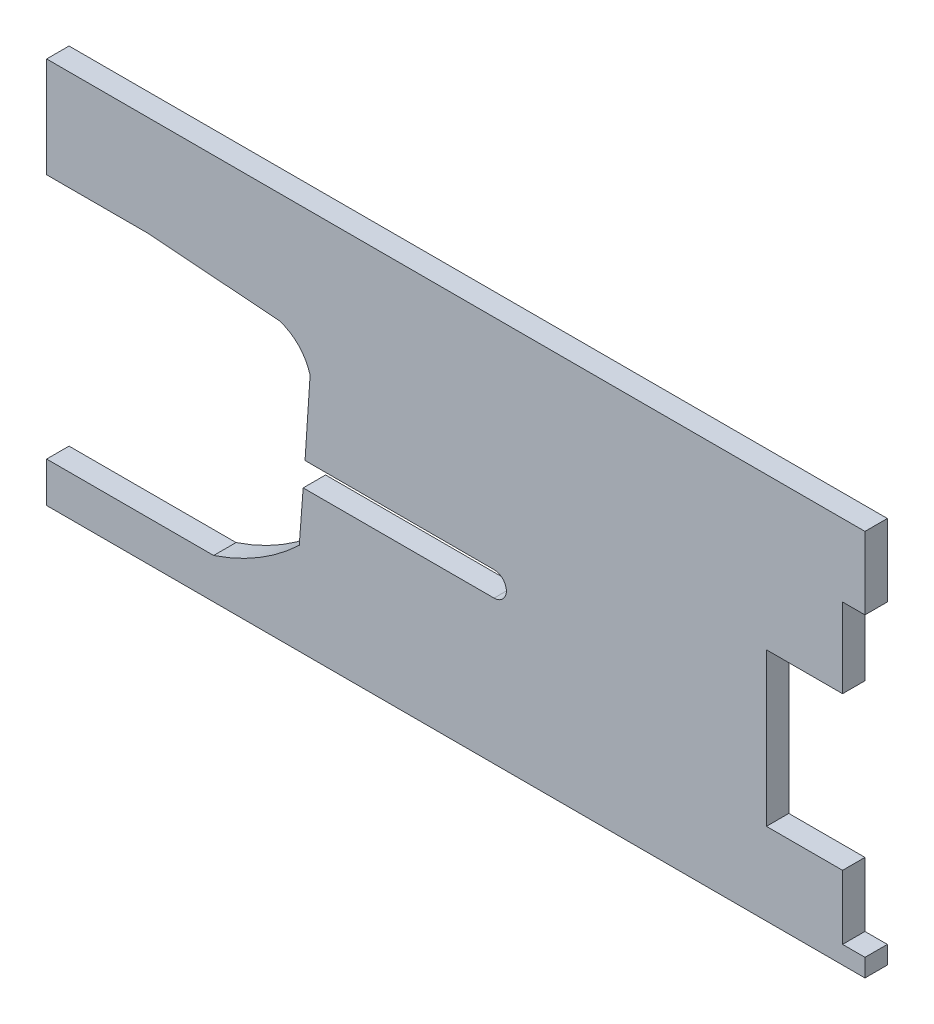
from build123d import *

# Parameters (mm, degrees)
BOSS_EXTRUDE1_DEPTH = 5


with BuildPart() as part:
    # Sketch1 → Boss-Extrude1 (new body)
    with BuildSketch(Plane.XY):
        with BuildLine():
            Line((-122.533931464, 0), (0, 0))
            Line((0, 0), (0, 4))
            Line((0, 4), (-5, 4))
            Line((-5, 4), (-5, 8.902615006))
            Line((-5, 8.902615006), (-5, 13.902615006))
            Line((-5, 13.902615006), (-5, 18.32224988))
            Line((-5, 18.32224988), (-22, 18.32224988))
            Line((-22, 18.32224988), (-22, 52.463633889))
            Line((-22, 52.463633889), (-5, 52.463633889))
            Line((-5, 52.463633889), (-5, 70.203021905))
            Line((-5, 70.203021905), (0, 70.203021905))
            Line((0, 70.203021905), (0, 86.350886134))
            Line((0, 86.350886134), (-182.7, 86.350886134))
            Line((-182.7, 86.350886134), (-182.7, 63.94896177))
            Line((-182.7, 63.94896177), (-160.256841342, 63.94896177))
            Line((-160.256841342, 63.94896177), (-130.724497172, 61.709515068))
            ThreePointArc((-130.724497172, 61.709515068), (-126.402059121, 59.039154196), (-123.878576155, 54.629354699))
            Line((-123.878576155, 54.629354699), (-125.011418309, 37.548381087))
            Line((-125.011418309, 37.548381087), (-82.810223158, 37.548381087))
            ThreePointArc((-82.810223158, 37.548381087), (-80.060223158, 34.798381087), (-82.810223158, 32.048381087))
            Line((-82.810223158, 32.048381087), (-125.427965277, 32.048381087))
            Line((-125.427965277, 32.048381087), (-126.301759952, 20.510976937))
            ThreePointArc((-126.301759952, 20.510976937), (-135.219115409, 13.694571486), (-145.410596187, 8.991771131))
            Line((-145.410596187, 8.991771131), (-182.7, 8.991771131))
            Line((-182.7, 8.991771131), (-182.7, 0))
            Line((-182.7, 0), (-122.533931464, 0))
        make_face()
    extrude(amount=BOSS_EXTRUDE1_DEPTH)


solid = part.part
